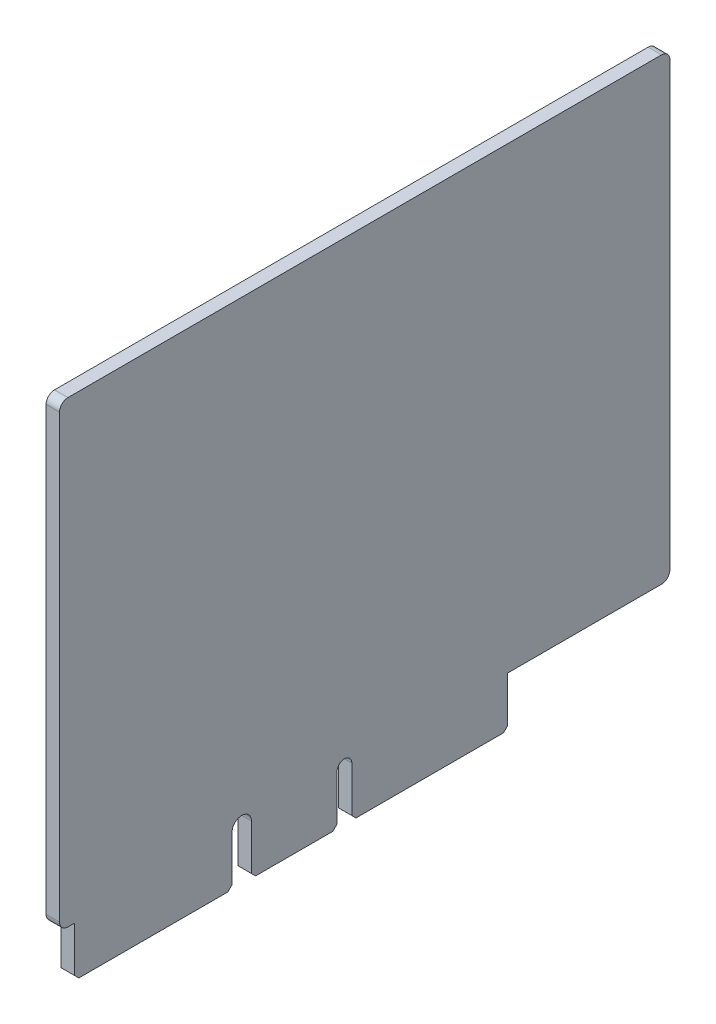
from build123d import *

# Parameters (mm, degrees)
BOSS_EXTRUDE1_DEPTH      = 0.8
BOSS_EXTRUDE1_DEPTH_BACK = 0.8
FILLET1_R                = 1


with BuildPart() as part:
    # Sketch2 → Boss-Extrude1 (new, two sides: drawn at the far end of the back side and taken through both)
    with BuildSketch(Plane(origin=(23.824934682, 0, 0), x_dir=(0, 0, -1), z_dir=(1, 0, 0)).offset(-BOSS_EXTRUDE1_DEPTH_BACK)):
        with BuildLine():
            Line((-65.407740568, 112.017340514), (7.473597983, 112.017340514))
            Line((7.473597983, 112.017340514), (7.473597983, 57.27523093))
            Line((7.473597983, 57.27523093), (-11.887740568, 57.27523093))
            Line((-11.887740568, 57.27523093), (-11.887740568, 51.84523093))
            Line((-11.887740568, 51.84523093), (-12.387740568, 51.34523093))
            Line((-12.387740568, 51.34523093), (-30.007740568, 51.34523093))
            Line((-30.007740568, 51.34523093), (-30.507740568, 51.84523093))
            Line((-30.507740568, 51.84523093), (-30.507740568, 57.27523093))
            ThreePointArc((-30.507740568, 57.27523093), (-31.387740568, 58.15523093), (-32.267740568, 57.27523093))
            Line((-32.267740568, 57.27523093), (-32.267740568, 51.84523093))
            Line((-32.267740568, 51.84523093), (-32.767740568, 51.34523093))
            Line((-32.767740568, 51.34523093), (-41.992740568, 51.34523093))
            Line((-41.992740568, 51.34523093), (-42.492740568, 51.84523093))
            Line((-42.492740568, 51.84523093), (-42.492740568, 57.27523093))
            ThreePointArc((-42.492740568, 57.27523093), (-43.647740568, 58.43023093), (-44.802740568, 57.27523093))
            Line((-44.802740568, 57.27523093), (-44.802740568, 51.84523093))
            Line((-44.802740568, 51.84523093), (-45.302740568, 51.34523093))
            Line((-45.302740568, 51.34523093), (-63.102740568, 51.34523093))
            Line((-63.102740568, 51.34523093), (-63.602740568, 51.84523093))
            Line((-63.602740568, 51.84523093), (-63.602740568, 57.27523093))
            Line((-63.602740568, 57.27523093), (-65.407740568, 57.27523093))
            Line((-65.407740568, 57.27523093), (-65.407740568, 112.017340514))
        make_face()
    extrude(amount=BOSS_EXTRUDE1_DEPTH + BOSS_EXTRUDE1_DEPTH_BACK)

    # Fillet1
    fillet1_edges = [part.edges().sort_by_distance(p)[0] for p in [
        (23.824934682, 57.27523093, 65.407740568),
        (23.824934682, 57.27523093, -7.473597983),
        (23.824934682, 112.017340514, -7.473597983),
        (23.824934682, 112.017340514, 65.407740568),
    ]]
    fillet(fillet1_edges, radius=FILLET1_R)


solid = part.part
